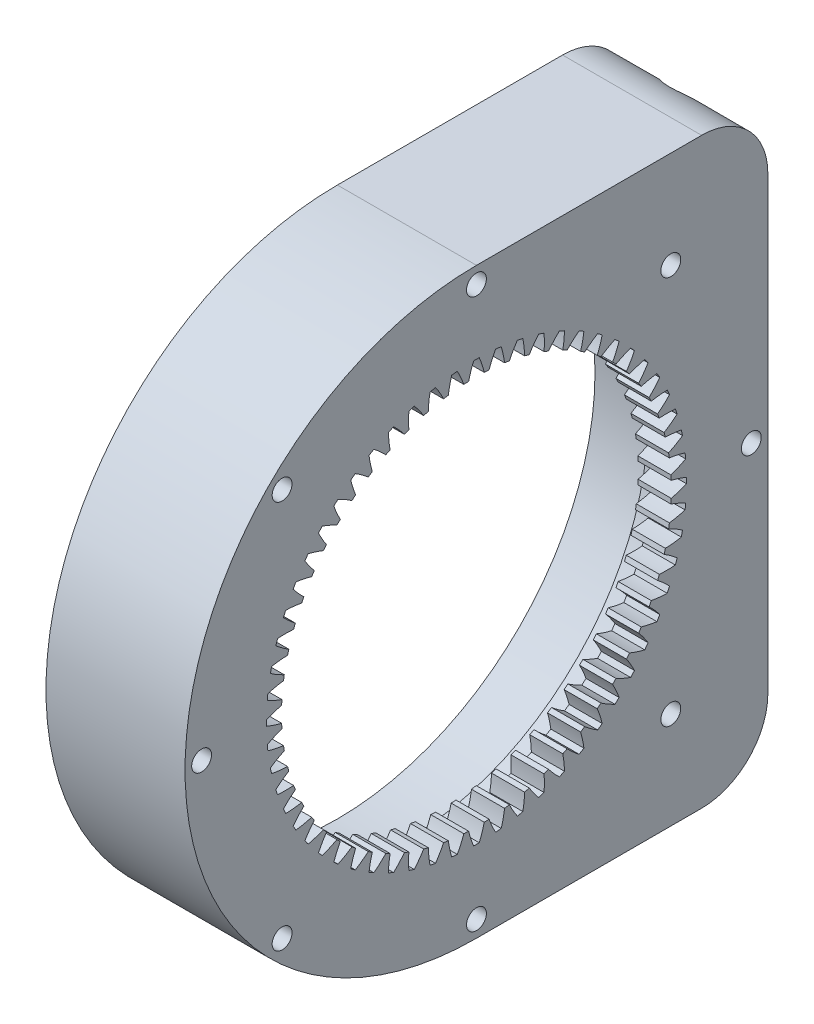
from build123d import *
from OCP.BRepFilletAPI import BRepFilletAPI_MakeChamfer

# Parameters (mm, degrees)
BASPROSKE_W         = 5
BASPROSKE_H         = 14.565
TOOTHCUT_DEPTH      = 63.42595614
TEETHCUTS_COUNT     = 60
SKETCH4_R           = 44
SKETCH4_R_2         = 38.9
BOSS_EXTRUDE3_DEPTH = 16
BOSS_EXTRUDE5_DEPTH = 21
BOSS_EXTRUDE6_DEPTH = 21
FILLET1_R           = 10
SKETCH14_R          = 38.9
SKETCH14_R_2        = 36.9
BOSS_EXTRUDE7_DEPTH = 6
SKETCH15_R          = 4.25
CUT_EXTRUDE1_DEPTH  = 20
CHAMFER1_SIZE       = 10
CHAMFER1_SIZE2      = 0.174550649
SKETCH16_R          = 1.5
CUT_EXTRUDE3_DEPTH  = 30
CIRPATTERN1_COUNT   = 8


with BuildPart() as part:
    # BasProSke → Base-Revolve (revolve)
    with BuildSketch(Plane(origin=(0, 0, 0), x_dir=(1, 0, 0), z_dir=(0, 1, 0)), mode=Mode.PRIVATE) as base_revolve_sk:
        with Locations((2.5, 36.7175)):
            Rectangle(BASPROSKE_W, BASPROSKE_H)
    revolve(base_revolve_sk.sketch.rotate(Axis((-10, 0, 0), (1, 0, 0)), 180), axis=Axis((-10, 0, 0), (1, 0, 0)))

    # TooCutSke → ToothCut (cut, through all)
    with BuildSketch(Plane(origin=(0, 0, 0), x_dir=(0, 0, -1), z_dir=(1, 0, 0))):
        with BuildLine():
            ThreePointArc((1.182891501, 29.385801671), (0.850504168, 30.566654642), (0.424126801, 31.71691436))
            ThreePointArc((0.424126801, 31.71691436), (0, 31.71975), (-0.424126801, 31.71691436))
            ThreePointArc((-0.424126801, 31.71691436), (-0.850504168, 30.566654642), (-1.182891501, 29.385801671))
            ThreePointArc((-1.182891501, 29.385801671), (0, 29.4096), (1.182891501, 29.385801671))
        make_face()
    toothcut = extrude(amount=TOOTHCUT_DEPTH, mode=Mode.SUBTRACT)

    # TeethCuts: ToothCut ×60 about axis
    teethcuts_axis = Axis((0, 0, 0), (1, 0, 0))
    for i in range(1, TEETHCUTS_COUNT):
        add(toothcut.rotate(teethcuts_axis, i * 360 / TEETHCUTS_COUNT), mode=Mode.SUBTRACT)

    # Sketch4 → Boss-Extrude3 (add)
    with BuildSketch(Plane.ZY):
        Circle(SKETCH4_R)
        Circle(SKETCH4_R_2, mode=Mode.SUBTRACT)
    extrude(amount=BOSS_EXTRUDE3_DEPTH)

    # Sketch7 → Boss-Extrude5 (add)
    with BuildSketch(Plane(origin=(5, 0, 0), x_dir=(0, 0, -1), z_dir=(1, 0, 0))):
        with BuildLine():
            Line((0, 44), (44, 44))
            Line((44, 44), (44, 0))
            ThreePointArc((44, 0), (31.112698372, 31.112698372), (0, 44))
        make_face()
    extrude(amount=-BOSS_EXTRUDE5_DEPTH)

    # Sketch10 → Boss-Extrude6 (add)
    with BuildSketch(Plane(origin=(5, 0, 0), x_dir=(0, 0, -1), z_dir=(1, 0, 0))):
        with BuildLine():
            Line((0, -44), (44, -44))
            Line((44, -44), (44, 0))
            ThreePointArc((44, 0), (31.112698372, -31.112698372), (0, -44))
        make_face()
    extrude(amount=-BOSS_EXTRUDE6_DEPTH)

    # Fillet1
    fillet1_edges = [part.edges().sort_by_distance(p)[0] for p in [
        (-5.5, 44, -44),
        (-5.5, -44, -44),
    ]]
    fillet(fillet1_edges, radius=FILLET1_R)

    # Sketch14 → Boss-Extrude7 (add)
    with BuildSketch(Plane.ZY):
        Circle(SKETCH14_R)
        Circle(SKETCH14_R_2, mode=Mode.SUBTRACT)
    extrude(amount=BOSS_EXTRUDE7_DEPTH)

    # Sketch15 → Cut-Extrude1 (cut)
    with BuildSketch(Plane(origin=(0, 0, -44), x_dir=(-1, 0, 0), z_dir=(0, 0, -1))):
        with Locations((5.5, -38)):
            Circle(SKETCH15_R)
        with Locations((5.5, 38)):
            Circle(SKETCH15_R)
    extrude(amount=-CUT_EXTRUDE1_DEPTH, mode=Mode.SUBTRACT)

    # Chamfer1: one chamfer whose edges measure the first distance from different faces: ONE call of the kernel's chamfer builder (chamfer() names one face for all edges)
    chamfer1_edges_1 = [part.edges().sort_by_distance(p)[0] for p in [
        (-1.25, -38, -24),
    ]]
    chamfer1_side_1 = [part.faces().sort_by_distance(p)[0] for p in [
        (-1.25, -38, -34),
    ]]
    chamfer1_edges_2 = [part.edges().sort_by_distance(p)[0] for p in [
        (-1.25, 38, -24),
    ]]
    chamfer1_side_2 = [part.faces().sort_by_distance(p)[0] for p in [
        (-1.25, 38, -34),
    ]]
    chamfer1 = BRepFilletAPI_MakeChamfer(part.part.solid().wrapped)
    for e in chamfer1_edges_1:
        chamfer1.Add(CHAMFER1_SIZE, CHAMFER1_SIZE2, e.wrapped, chamfer1_side_1[0].wrapped)  # the first distance lies on this face
    for e in chamfer1_edges_2:
        chamfer1.Add(CHAMFER1_SIZE, CHAMFER1_SIZE2, e.wrapped, chamfer1_side_2[0].wrapped)  # the first distance lies on this face
    add(Compound.cast(chamfer1.Shape()), mode=Mode.REPLACE)

    # Sketch16 → Cut-Extrude3 (cut)
    with BuildSketch(Plane.ZY.offset(16)):
        with Locations((41.5, 0)):
            Circle(SKETCH16_R)
    cut_extrude3 = extrude(amount=-CUT_EXTRUDE3_DEPTH, mode=Mode.SUBTRACT)

    # CirPattern1: Cut-Extrude3 ×8 about axis
    cirpattern1_axis = Axis((0, 0, 0), (1, 0, 0))
    for i in range(1, CIRPATTERN1_COUNT):
        add(cut_extrude3.rotate(cirpattern1_axis, i * 360 / CIRPATTERN1_COUNT), mode=Mode.SUBTRACT)


solid = part.part
